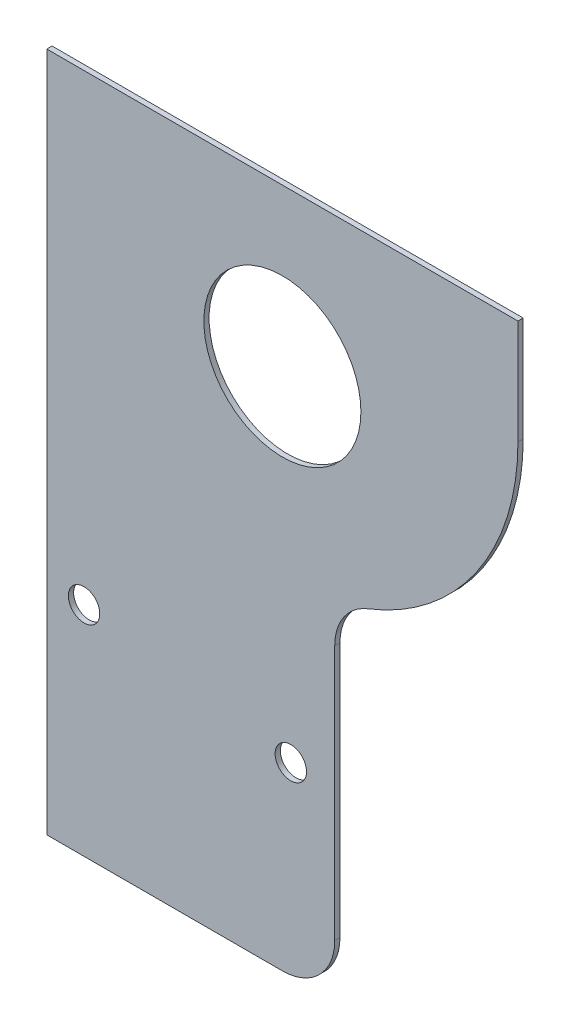
from build123d import *

# Parameters (mm, degrees)
SKETCH1_R           = 15
BOSS_EXTRUDE1_DEPTH = 1
CUT_EXTRUDE1_DEPTH  = 10


with BuildPart() as part:
    # Sketch1 → Boss-Extrude1 (new body)
    with BuildSketch(Plane(origin=(0, 0, 0), x_dir=(-1, 0, 0), z_dir=(0, 0, -1))):
        with BuildLine():
            Line((0, -75), (0, 0))
            Line((0, 0), (-90, 0))
            Line((-90, 0), (-90, -20))
            ThreePointArc((-90, -20), (-82.157527073, -45.383423367), (-61.363636364, -61.919344043))
            ThreePointArc((-61.363636364, -61.919344043), (-56.742771762, -65.593993082), (-55, -71.23475383))
            Line((-55, -71.23475383), (-55, -120))
            ThreePointArc((-55, -120), (-52.071067812, -127.071067812), (-45, -130))
            Line((-45, -130), (0, -130))
            Line((0, -130), (0, -75))
        make_face()
        with Locations((-45, -30)):
            Circle(SKETCH1_R, mode=Mode.SUBTRACT)
    extrude(amount=-BOSS_EXTRUDE1_DEPTH)

    # Sketch2 → Cut-Extrude1 (cut)
    with BuildSketch(Plane(origin=(0, 0, 0), x_dir=(-1, 0, 0), z_dir=(0, 0, -1))):
        with BuildLine():
            ThreePointArc((-43.646562299, -94.279689067), (-47.086223708, -91.795996374), (-49.569916401, -95.235657783))
            ThreePointArc((-49.569916401, -95.235657783), (-46.130254992, -97.719350476), (-43.646562299, -94.279689067))
        make_face()
        with BuildLine():
            ThreePointArc((-10.080889056, -88.862533012), (-6.641227647, -91.346225705), (-4.157534954, -87.906564297))
            ThreePointArc((-4.157534954, -87.906564297), (-7.597196363, -85.422871604), (-10.080889056, -88.862533012))
        make_face()
    extrude(amount=-CUT_EXTRUDE1_DEPTH, mode=Mode.SUBTRACT)


solid = part.part
